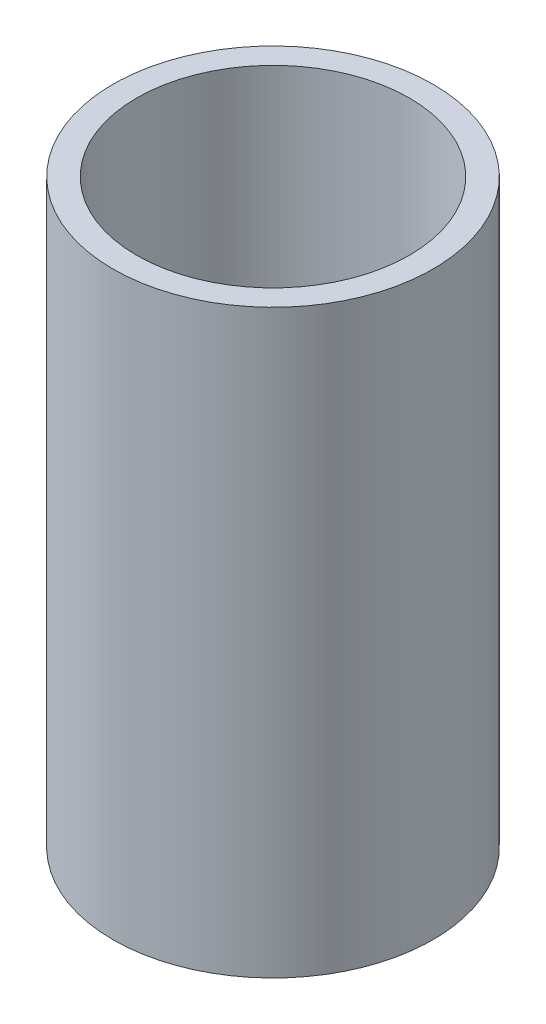
from build123d import *

# Parameters (mm, degrees)
SKETCH1_R           = 13.5
SKETCH1_R_2         = 11.5
BOSS_EXTRUDE1_DEPTH = 49


with BuildPart() as part:
    # Sketch1 → Boss-Extrude1 (new body)
    with BuildSketch(Plane(origin=(0, 0, 0), x_dir=(1, 0, 0), z_dir=(0, 1, 0))):
        Circle(SKETCH1_R)
        Circle(SKETCH1_R_2, mode=Mode.SUBTRACT)
    extrude(amount=BOSS_EXTRUDE1_DEPTH)


solid = part.part
